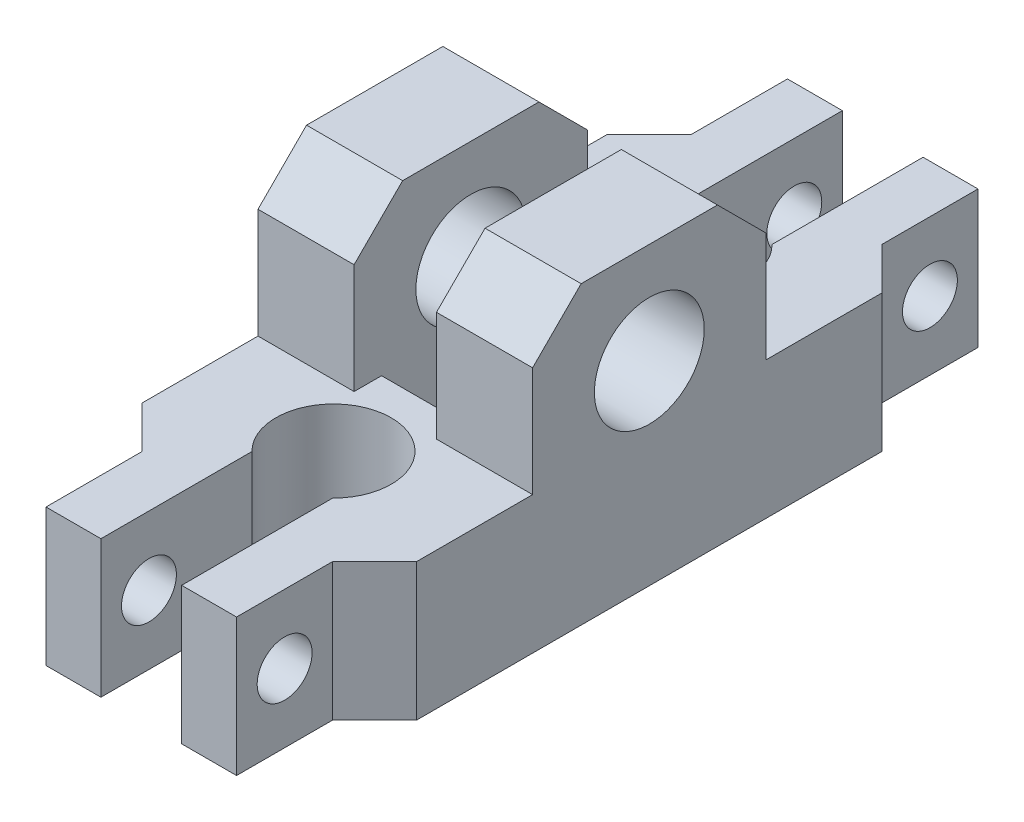
from build123d import *

# Parameters (mm, degrees)
SKETCH1_W           = 4
SKETCH1_H           = 7
BOSS_EXTRUDE1_DEPTH = 10
SKETCH2_R           = 4
BOSS_EXTRUDE2_DEPTH = 20
SKETCH3_W           = 6
SKETCH3_H           = 13
CUT_EXTRUDE1_DEPTH  = 16
SKETCH4_W           = 6
SKETCH4_H           = 10
CUT_EXTRUDE2_DEPTH  = 36.5
SKETCH5_R           = 2
CUT_EXTRUDE3_DEPTH  = 17.939387691
CUT_EXTRUDE4_DEPTH  = 10


with BuildPart() as part:
    # Sketch1 → Boss-Extrude1 (new body)
    with BuildSketch(Plane(origin=(0, 0, 0), x_dir=(1, 0, 0), z_dir=(0, 1, 0))):
        with BuildLine():
            Line((0, 40), (0, 0))
            Line((0, 0), (3.060612309, 0))
            Line((3.060612309, 0), (7.060612309, 0))
            Line((7.060612309, 0), (7.060612309, 4))
            ThreePointArc((7.060612309, 4), (8.372951799, 10.872042633), (14.2, 7))
            ThreePointArc((14.2, 7), (13.872042633, 5.372951799), (12.939387691, 4))
            Line((12.939387691, 4), (12.939387691, 0))
            Line((12.939387691, 0), (16.939387691, 0))
            Line((16.939387691, 0), (20, 0))
            Line((20, 0), (20, 40))
            Line((20, 40), (16.939387691, 40))
            Line((16.939387691, 40), (12.939387691, 40))
            Line((12.939387691, 40), (12.939387691, 36))
            ThreePointArc((12.939387691, 36), (13.872042633, 34.627048201), (14.2, 33))
            ThreePointArc((14.2, 33), (8.372951799, 29.127957367), (7.060612309, 36))
            Line((7.060612309, 36), (7.060612309, 40))
            Line((7.060612309, 40), (3.060612309, 40))
            Line((3.060612309, 40), (0, 40))
        make_face()
        with Locations((14.939387691, -3.5)):
            Rectangle(SKETCH1_W, SKETCH1_H)
        with Locations((5.060612309, -3.5)):
            Rectangle(SKETCH1_W, SKETCH1_H)
        with Locations((14.939387691, 43.5)):
            Rectangle(SKETCH1_W, SKETCH1_H)
        with Locations((5.060612309, 43.5)):
            Rectangle(SKETCH1_W, SKETCH1_H)
    extrude(amount=BOSS_EXTRUDE1_DEPTH)

    # Sketch2 → Boss-Extrude2 (add)
    with BuildSketch(Plane(origin=(20, 0, 0), x_dir=(0, 0, -1), z_dir=(1, 0, 0))):
        Polygon((28.5, 0), (11.5, 0), (11.5, 18), (15.035533906, 21.535533906), (24.964466094, 21.535533906), (28.5, 18), align=None)
        with Locations((20, 14.190533906)):
            Circle(SKETCH2_R, mode=Mode.SUBTRACT)
    extrude(amount=-BOSS_EXTRUDE2_DEPTH)

    # Sketch3 → Cut-Extrude1 (cut)
    with BuildSketch(Plane(origin=(0, 21.535533906, 0), x_dir=(1, 0, 0), z_dir=(0, 1, 0))):
        with Locations((10, 20)):
            Rectangle(SKETCH3_W, SKETCH3_H)
    extrude(amount=-CUT_EXTRUDE1_DEPTH, mode=Mode.SUBTRACT)

    # Sketch4 → Cut-Extrude2 (cut, through all)
    with BuildSketch(Plane.XY.offset(-11.5)):
        with Locations((10, 15)):
            Rectangle(SKETCH4_W, SKETCH4_H)
    extrude(amount=-CUT_EXTRUDE2_DEPTH, mode=Mode.SUBTRACT)

    # Sketch5 → Cut-Extrude3 (cut, through all)
    with BuildSketch(Plane.ZY.offset(-3.060612309)):
        with Locations((3.5, 5)):
            Circle(SKETCH5_R)
        with Locations((-43.5, 5)):
            Circle(SKETCH5_R)
    extrude(amount=-CUT_EXTRUDE3_DEPTH, mode=Mode.SUBTRACT)

    # Sketch6 → Cut-Extrude4 (cut)
    with BuildSketch(Plane(origin=(0, 10, 0), x_dir=(1, 0, 0), z_dir=(0, 1, 0))):
        Polygon((16.939387691, 40), (20, 36.939387691), (20, 40), align=None)
        Polygon((0, 40), (3.060612309, 40), (0, 36.939387691), align=None)
        Polygon((3.060612309, 0), (0, 3.060612309), (0, 0), align=None)
        Polygon((20, 0), (16.939387691, 0), (20, 3.060612309), align=None)
    extrude(amount=-CUT_EXTRUDE4_DEPTH, mode=Mode.SUBTRACT)


solid = part.part
